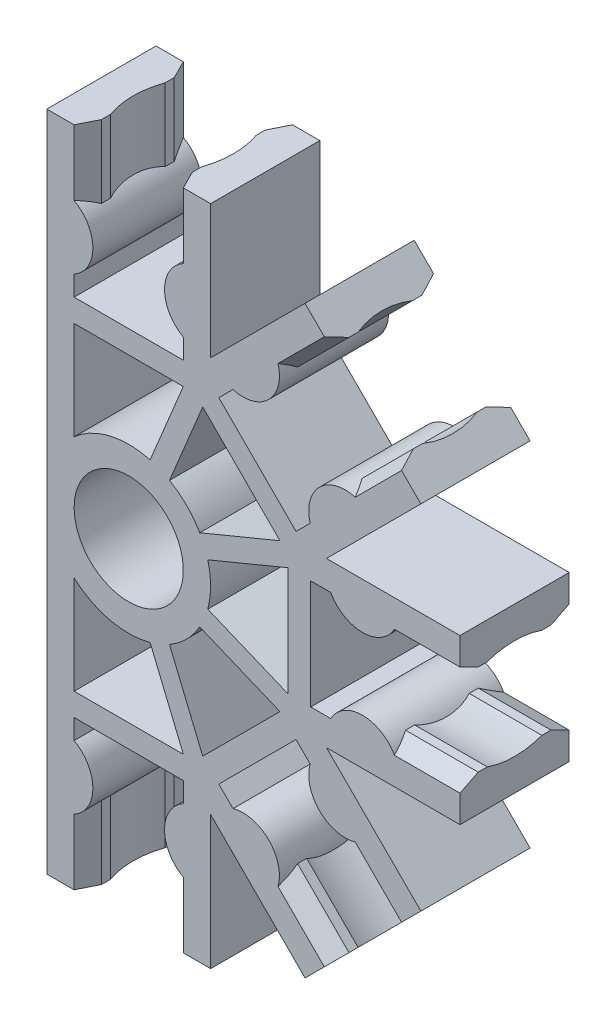
from build123d import *

# Parameters (mm, degrees)
EXTRUDE_1_DEPTH          = 6
EXTRUDE_2_REACH          = 25.907
PATTERN_CIRCULAR_1_COUNT = 5
PATTERN_CIRCULAR_1_ANGLE = 180
SKETCH_4_R               = 3
CUT_EXTRUDE_1_DEPTH      = 27.42877236


with BuildPart() as part:
    # 草图1 → 凸台-拉伸1 (new body)
    with BuildSketch(Plane.XY):
        with BuildLine():
            Line((-4.5, 0), (-4.5, -18.2))
            Line((-4.5, -18.2), (-3, -18.2))
            Line((-3, -18.2), (-3, -14.6))
            ThreePointArc((-3, -14.6), (-1.968245837, -12.85), (-3, -11.1))
            Line((-3, -11.1), (-3, -10))
            Line((-3, -10), (3, -10))
            Line((3, -10), (3, -11.1))
            ThreePointArc((3, -11.1), (1.968245837, -12.85), (3, -14.6))
            Line((3, -14.6), (3, -18.2))
            Line((3, -18.2), (4.5, -18.2))
            Line((4.5, -18.2), (4.5, 0))
            ThreePointArc((4.5, 0), (0, 4.5), (-4.5, 0))
        make_face()
    extrude_1 = extrude(amount=EXTRUDE_1_DEPTH)

    # 草图3 → 凸台-拉伸2 (add, up to next)
    with BuildSketch(Plane.XZ.offset(18.2), mode=Mode.PRIVATE) as extrude_2_sk1:
        with BuildLine():
            Line((-3, 6), (-3, 0))
            Line((-3, 0), (-2.5, 1))
            Line((-2.5, 1), (-2.5, 1.5))
            ThreePointArc((-2.5, 1.5), (-2.757359313, 3), (-2.5, 4.5))
            Line((-2.5, 4.5), (-2.5, 5))
            Line((-2.5, 5), (-3, 6))
        make_face()
    extrude_2_tool1 = extrude(extrude_2_sk1.sketch, amount=-EXTRUDE_2_REACH, mode=Mode.PRIVATE) - part.part
    # 草图3 → 凸台-拉伸2 (add, up to next)
    with BuildSketch(Plane.XZ.offset(18.2), mode=Mode.PRIVATE) as extrude_2_sk2:
        with BuildLine():
            Line((3, 0), (2.5, 1))
            Line((2.5, 1), (2.5, 1.5))
            ThreePointArc((2.5, 1.5), (2.757359313, 3), (2.5, 4.5))
            Line((2.5, 4.5), (2.5, 5))
            Line((2.5, 5), (3, 6))
            Line((3, 6), (3, 0))
        make_face()
    extrude_2_tool2 = extrude(extrude_2_sk2.sketch, amount=-EXTRUDE_2_REACH, mode=Mode.PRIVATE) - part.part
    extrude_2_1 = extrude_2_tool1.solids().sort_by_distance((-2.809362, -18.2, 3))[0]
    add(extrude_2_1)
    extrude_2_2 = extrude_2_tool2.solids().sort_by_distance((2.809362, -18.2, 3))[0]
    add(extrude_2_2)
    extrude_2 = extrude_2_1 + extrude_2_2  # 凸台-拉伸2 as one shape, for the pattern or mirror that repeats it

    # 阵列(圆周)1: 凸台-拉伸1, 凸台-拉伸2 ×5 about axis
    pattern_circular_1_axis = Axis((0, 0, 0), (0, 0, 1))
    add([extrude_1.rotate(pattern_circular_1_axis, i * PATTERN_CIRCULAR_1_ANGLE / (PATTERN_CIRCULAR_1_COUNT - 1)) for i in range(1, PATTERN_CIRCULAR_1_COUNT)])
    add([extrude_2.rotate(pattern_circular_1_axis, i * PATTERN_CIRCULAR_1_ANGLE / (PATTERN_CIRCULAR_1_COUNT - 1)) for i in range(1, PATTERN_CIRCULAR_1_COUNT)])

    # 草图4 → 切除-拉伸1 (cut, through all)
    with BuildSketch(Plane(origin=(0, 0, 0), x_dir=(-1, 0, 0), z_dir=(0, 0, -1))):
        Circle(SKETCH_4_R)
        with BuildLine():
            Line((3, -8.75), (3, -3.354101966))
            ThreePointArc((3, -3.354101966), (1.038095674, -4.378625055), (-1.174936357, -4.343906601))
            Line((-1.174936357, -4.343906601), (-3, -8.75))
            Line((-3, -8.75), (3, -8.75))
        make_face()
        with BuildLine():
            Line((-4.065863992, -8.308504679), (-8.308504679, -4.065863992))
            Line((-8.308504679, -4.065863992), (-3.90241128, -2.240800349))
            ThreePointArc((-3.90241128, -2.240800349), (-3.181980515, -3.181980515), (-2.240800349, -3.90241128))
            Line((-2.240800349, -3.90241128), (-4.065863992, -8.308504679))
        make_face()
        with BuildLine():
            Line((3, 8.75), (3, 3.354101966))
            ThreePointArc((3, 3.354101966), (1.038095674, 4.378625055), (-1.174936357, 4.343906601))
            Line((-1.174936357, 4.343906601), (-3, 8.75))
            Line((-3, 8.75), (3, 8.75))
        make_face()
        with BuildLine():
            Line((-8.75, 3), (-4.343906601, 1.174936357))
            ThreePointArc((-4.343906601, 1.174936357), (-4.5, 0), (-4.343906601, -1.174936357))
            Line((-4.343906601, -1.174936357), (-8.75, -3))
            Line((-8.75, -3), (-8.75, 3))
        make_face()
        with BuildLine():
            Line((-4.065863992, 8.308504679), (-2.240800349, 3.90241128))
            ThreePointArc((-2.240800349, 3.90241128), (-3.181980515, 3.181980515), (-3.90241128, 2.240800349))
            Line((-3.90241128, 2.240800349), (-8.308504679, 4.065863992))
            Line((-8.308504679, 4.065863992), (-4.065863992, 8.308504679))
        make_face()
    extrude(amount=-CUT_EXTRUDE_1_DEPTH, mode=Mode.SUBTRACT)


solid = part.part
